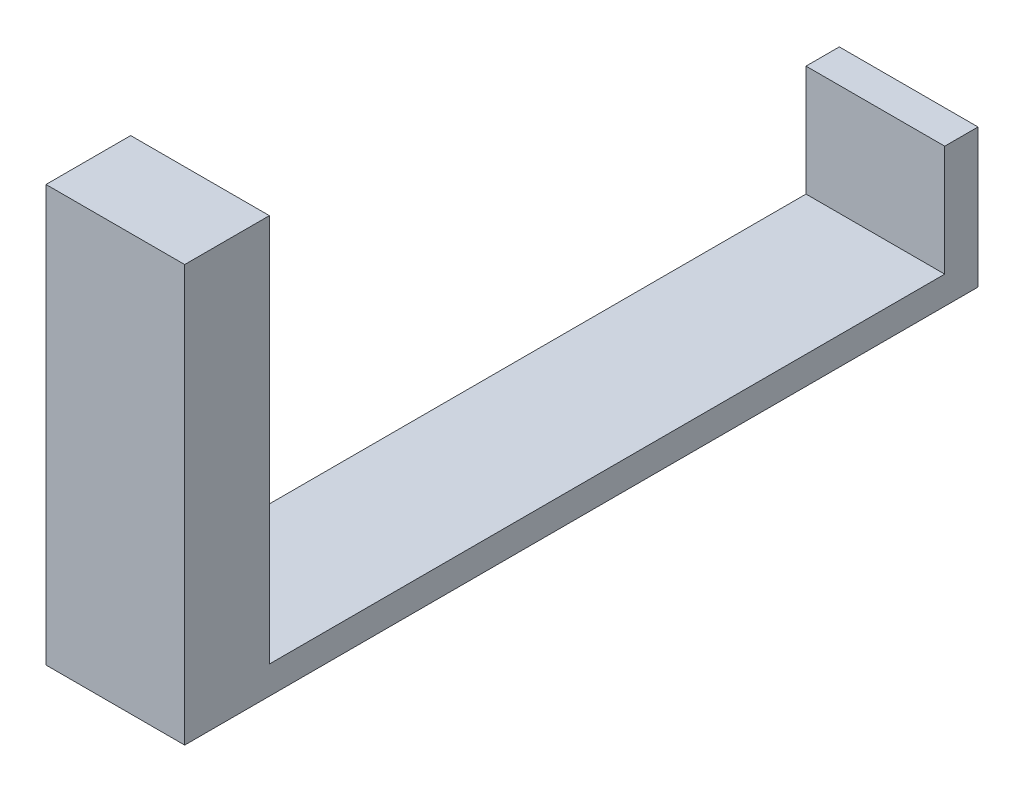
from build123d import *

# Parameters (mm, degrees)
SKETCH1_W           = 250
SKETCH1_H           = 250
BOSS_EXTRUDE1_DEPTH = 60
SKETCH2_W           = 250
SKETCH2_H           = 50.233662696
BOSS_EXTRUDE2_DEPTH = 1370
SKETCH3_W           = 250
SKETCH3_H           = 152.663953539
BOSS_EXTRUDE3_DEPTH = 700


with BuildPart() as part:
    # Sketch1 → Boss-Extrude1 (new body)
    with BuildSketch(Plane.XY):
        with Locations((-125, 125)):
            Rectangle(SKETCH1_W, SKETCH1_H)
    extrude(amount=BOSS_EXTRUDE1_DEPTH)

    # Sketch2 → Boss-Extrude2 (add)
    with BuildSketch(Plane.XY.offset(60)):
        with Locations((-125, 25.116831348)):
            Rectangle(SKETCH2_W, SKETCH2_H)
    extrude(amount=BOSS_EXTRUDE2_DEPTH)

    # Sketch3 → Boss-Extrude3 (add)
    with BuildSketch(Plane(origin=(0, 50.233662696, 0), x_dir=(1, 0, 0), z_dir=(0, 1, 0))):
        with Locations((-125, -1353.668023231)):
            Rectangle(SKETCH3_W, SKETCH3_H)
    extrude(amount=BOSS_EXTRUDE3_DEPTH)


solid = part.part
